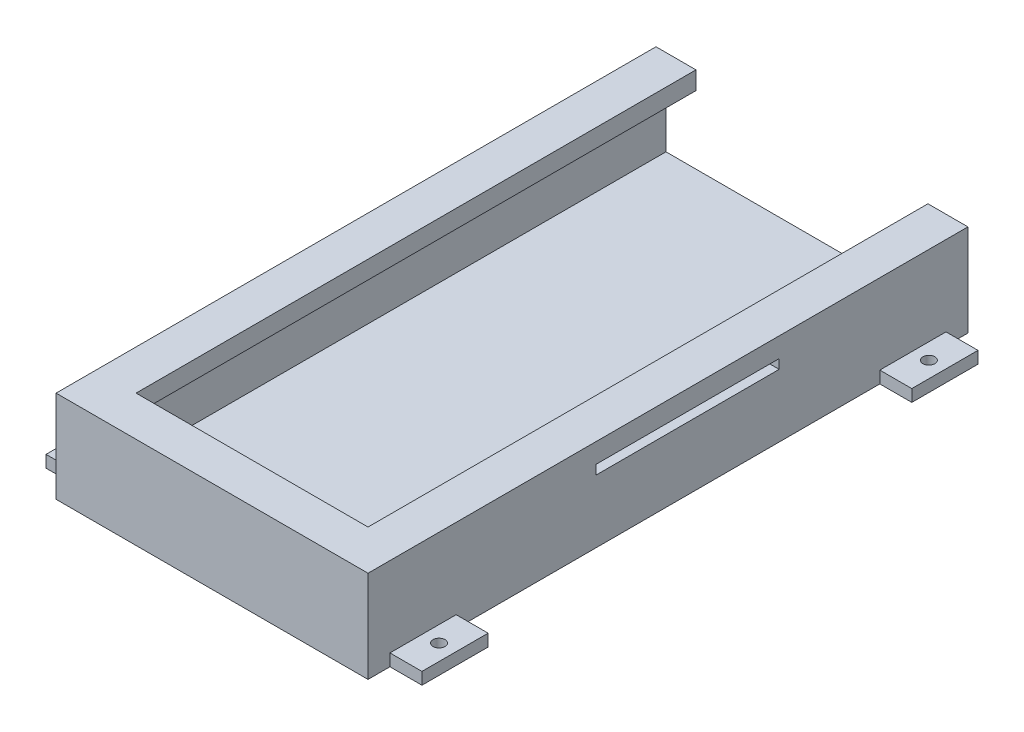
from build123d import *

# Parameters (mm, degrees)
IZIM1_W                     = 78
IZIM1_H                     = 150
Y_KSEKLIK_EKSTR_ZYON1_DEPTH = 18
IZIM2_W                     = 73
IZIM2_H                     = 17
KES_EKSTR_ZYON1_DEPTH       = 143
IZIM3_W                     = 78
IZIM3_H                     = 150
Y_KSEKLIK_EKSTR_ZYON2_DEPTH = 5
IZIM4_W                     = 73
IZIM4_H                     = 17
KES_EKSTR_ZYON2_DEPTH       = 148
IZIM6_W                     = 58
IZIM6_H                     = 130
IZIM6_H_2                   = 10
KES_EKSTR_ZYON3_DEPTH       = 10
IZIM7_W                     = 45.739377618
IZIM7_H                     = 2.329706958
KES_EKSTR_ZYON5_DEPTH       = 147
IZIM8_W                     = 94
IZIM8_H                     = 16.552930253
Y_KSEKLIK_EKSTR_ZYON4_DEPTH = 3
IZIM10_W                    = 73
IZIM10_H                    = 17
KES_EKSTR_ZYON7_DEPTH       = 146
IZIM11_R                    = 1.5
KES_EKSTR_ZYON8_DEPTH       = 146


with BuildPart() as part:
    # Çizim1 → Yükseklik-Ekstrüzyon1 (new body)
    with BuildSketch(Plane(origin=(0, 0, 0), x_dir=(1, 0, 0), z_dir=(0, 1, 0))):
        with Locations((8.016202101, 19.801973492)):
            Rectangle(IZIM1_W, IZIM1_H)
    extrude(amount=Y_KSEKLIK_EKSTR_ZYON1_DEPTH)

    # Çizim2 → Kes-Ekstrüzyon1 (cut)
    with BuildSketch(Plane(origin=(0, 0, -94.801973492), x_dir=(-1, 0, 0), z_dir=(0, 0, -1))):
        with Locations((-8.016202101, 10)):
            Rectangle(IZIM2_W, IZIM2_H)
    extrude(amount=-KES_EKSTR_ZYON1_DEPTH, mode=Mode.SUBTRACT)

    # Çizim3 → Yükseklik-Ekstrüzyon2 (add)
    with BuildSketch(Plane(origin=(0, 18, 0), x_dir=(1, 0, 0), z_dir=(0, 1, 0))):
        with Locations((8.016202101, 19.801973492)):
            Rectangle(IZIM3_W, IZIM3_H)
    extrude(amount=Y_KSEKLIK_EKSTR_ZYON2_DEPTH)

    # Çizim4 → Kes-Ekstrüzyon2 (cut)
    with BuildSketch(Plane(origin=(0, 0, -94.801973492), x_dir=(-1, 0, 0), z_dir=(0, 0, -1))):
        with Locations((-8.016202101, 10)):
            Rectangle(IZIM4_W, IZIM4_H)
    extrude(amount=-KES_EKSTR_ZYON2_DEPTH, mode=Mode.SUBTRACT)

    # Çizim6 → Kes-Ekstrüzyon3 (cut)
    with BuildSketch(Plane(origin=(0, 23, 0), x_dir=(1, 0, 0), z_dir=(0, 1, 0))):
        with Locations((8.016202101, 19.801973492)):
            Rectangle(IZIM6_W, IZIM6_H)
        with Locations((8.016202101, 89.801973492)):
            Rectangle(IZIM6_W, IZIM6_H_2)
    extrude(amount=-KES_EKSTR_ZYON3_DEPTH, mode=Mode.SUBTRACT)

    # Çizim7 → Kes-Ekstrüzyon5 (cut)
    with BuildSketch(Plane(origin=(47.016202101, 0, 0), x_dir=(0, 0, -1), z_dir=(1, 0, 0))):
        with Locations((24.733454375, 16.908564322)):
            Rectangle(IZIM7_W, IZIM7_H)
    extrude(amount=-KES_EKSTR_ZYON5_DEPTH, mode=Mode.SUBTRACT)

    # Çizim8 → Yükseklik-Ekstrüzyon4 (add)
    with BuildSketch(Plane.XZ):
        with Locations((8.016202101, 41.439700866)):
            Rectangle(IZIM8_W, IZIM8_H)
        with Locations((8.016202101, -81.04364785)):
            Rectangle(IZIM8_W, IZIM8_H)
    extrude(amount=-Y_KSEKLIK_EKSTR_ZYON4_DEPTH)

    # Çizim10 → Kes-Ekstrüzyon7 (cut)
    with BuildSketch(Plane(origin=(0, 0, -94.801973492), x_dir=(-1, 0, 0), z_dir=(0, 0, -1))):
        with Locations((-8.016202101, 10)):
            Rectangle(IZIM10_W, IZIM10_H)
    extrude(amount=-KES_EKSTR_ZYON7_DEPTH, mode=Mode.SUBTRACT)

    # Çizim11 → Kes-Ekstrüzyon8 (cut)
    with BuildSketch(Plane(origin=(0, 3, 0), x_dir=(1, 0, 0), z_dir=(0, 1, 0))):
        with Locations((-34.983797899, -41.439700866)):
            Circle(IZIM11_R)
        with Locations((51.016202101, -41.439700866)):
            Circle(IZIM11_R)
        with Locations((51.016202101, 81.043647849)):
            Circle(IZIM11_R)
        with Locations((-34.983797899, 81.043647849)):
            Circle(IZIM11_R)
    extrude(amount=-KES_EKSTR_ZYON8_DEPTH, mode=Mode.SUBTRACT)


solid = part.part
